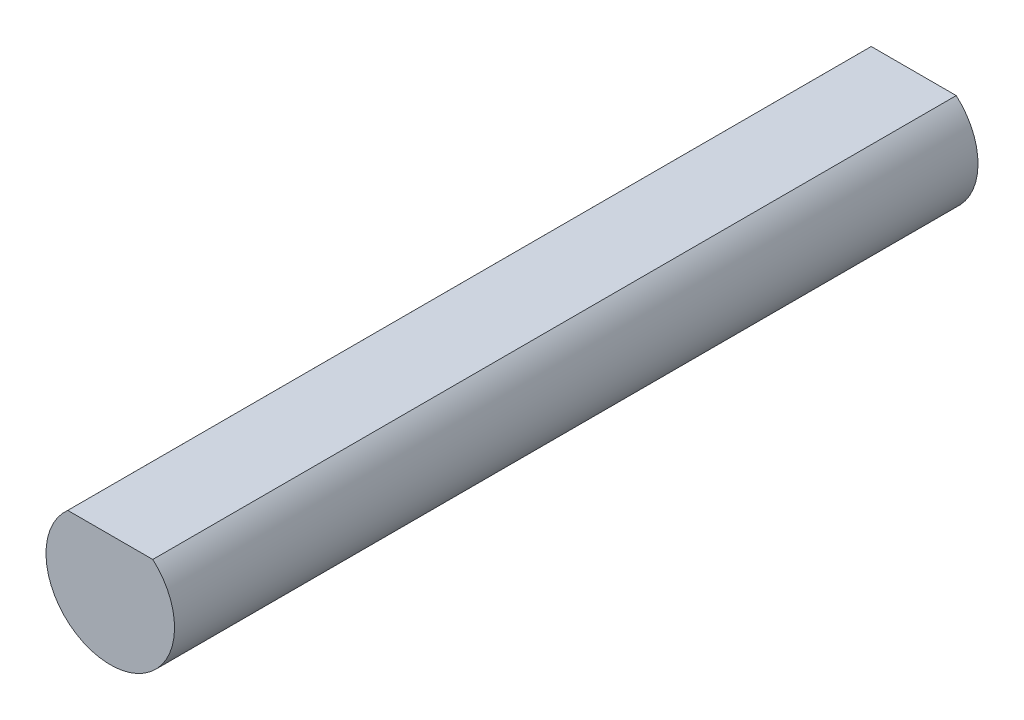
from build123d import *

# Parameters (mm, degrees)
BOSS_EXTRUDE1_DEPTH = 25


with BuildPart() as part:
    # Sketch1 → Boss-Extrude1 (new body)
    with BuildSketch(Plane.XY):
        with BuildLine():
            Line((-1.322875656, 1.5), (1.322875656, 1.5))
            ThreePointArc((1.322875656, 1.5), (0, -2), (-1.322875656, 1.5))
        make_face()
    extrude(amount=BOSS_EXTRUDE1_DEPTH)


solid = part.part
